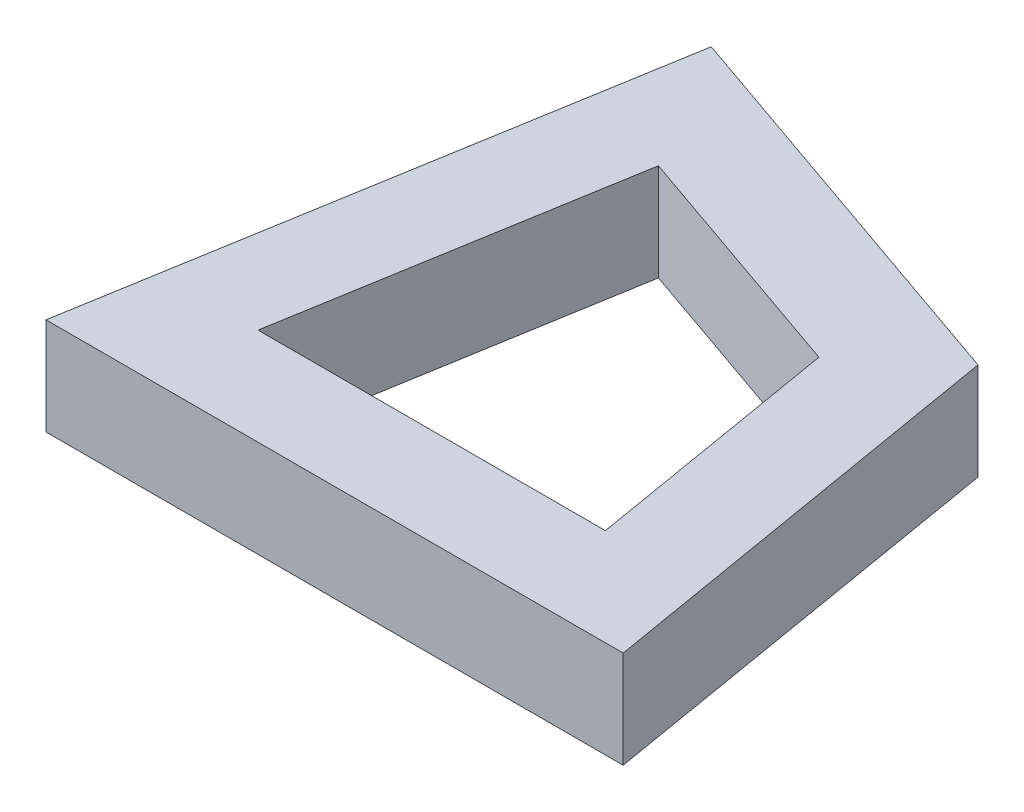
from build123d import *

# Parameters (mm, degrees)
BOSS_EXTRUDE1_DEPTH = 2


with BuildPart() as part:
    # Sketch1 → Boss-Extrude1 (new body)
    with BuildSketch(Plane(origin=(0, 0, 0), x_dir=(1, 0, 0), z_dir=(0, 1, 0))):
        Polygon((0, 0), (11.884426, 0), (10.399016729, 8.791598271), (1.979905623, 11.718342676), align=None)
        Polygon((3.557821105, 9.052408703), (2.366261511, 2), (9.518164489, 2), (8.624177239, 7.291186018), align=None, mode=Mode.SUBTRACT)
    extrude(amount=BOSS_EXTRUDE1_DEPTH)


solid = part.part
